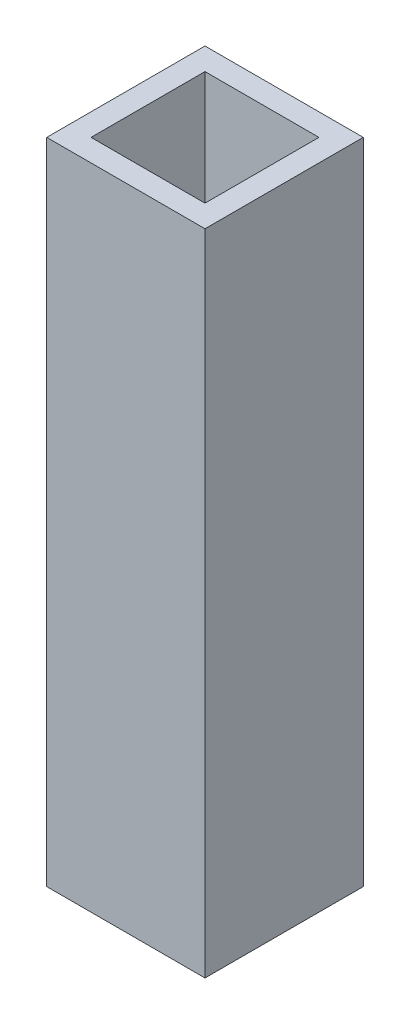
from build123d import *

# Parameters (mm, degrees)
SKETCH1_W           = 50
SKETCH1_H           = 50
SKETCH1_W_2         = 36
SKETCH1_H_2         = 36
BOSS_EXTRUDE1_DEPTH = 205


with BuildPart() as part:
    # Sketch1 → Boss-Extrude1 (new body)
    with BuildSketch(Plane(origin=(0, 0, 0), x_dir=(1, 0, 0), z_dir=(0, 1, 0))):
        Rectangle(SKETCH1_W, SKETCH1_H)
        Rectangle(SKETCH1_W_2, SKETCH1_H_2, mode=Mode.SUBTRACT)
    extrude(amount=BOSS_EXTRUDE1_DEPTH)


solid = part.part
